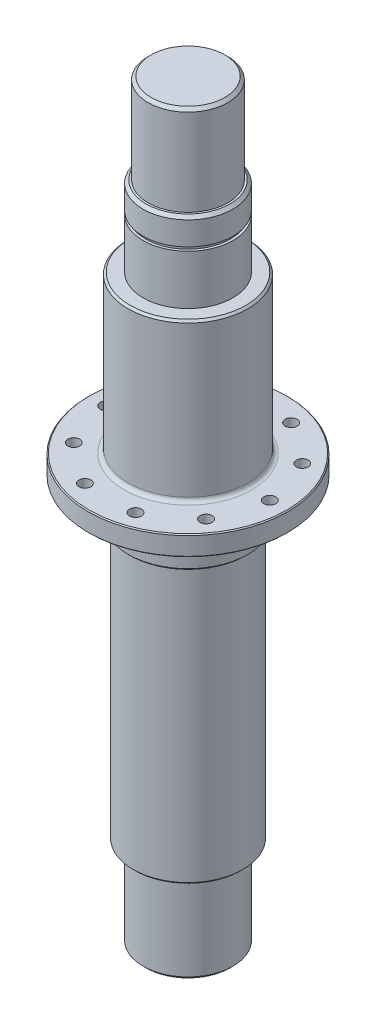
from build123d import *

# Parameters (mm, degrees)
SKIZZE1_R                       = 50
AUFSATZ_LINEAR_AUSTRAGEN1_DEPTH = 10
SKIZZE2_R                       = 3
SCHNITT_LINEAR_AUSTRAGEN2_DEPTH = 10
SKIZZE3_R                       = 30
AUFSATZ_LINEAR_AUSTRAGEN2_DEPTH = 78.6
VERRUNDUNG1_R                   = 2
FASE1_SIZE                      = 1
SKIZZE4_R                       = 22.5
AUFSATZ_LINEAR_AUSTRAGEN3_DEPTH = 24.9
SKIZZE5_R                       = 21.25
AUFSATZ_LINEAR_AUSTRAGEN4_DEPTH = 1.85
SKIZZE6_R                       = 22.5
AUFSATZ_LINEAR_AUSTRAGEN5_DEPTH = 13.25
FASE2_SIZE                      = 1.5
SKIZZE7_R                       = 20
AUFSATZ_LINEAR_AUSTRAGEN6_DEPTH = 45
FASE3_SIZE                      = 1.5
SKIZZE8_R                       = 30
AUFSATZ_LINEAR_AUSTRAGEN7_DEPTH = 20
FASE4_SIZE                      = 1
VERRUNDUNG2_R                   = 2
FASE5_SIZE                      = 0.5
FASE6_SIZE                      = 0.5
SKIZZE9_R                       = 27.5
AUFSATZ_LINEAR_AUSTRAGEN8_DEPTH = 138
SKIZZE10_R                      = 22.5
AUFSATZ_LINEAR_AUSTRAGEN9_DEPTH = 45
VERRUNDUNG3_R                   = 1
FASE7_SIZE                      = 1
VERRUNDUNG4_R                   = 1
FASE8_SIZE                      = 1.5


with BuildPart() as part:
    # Skizze1 → Aufsatz-Linear austragen1 (new body)
    with BuildSketch(Plane(origin=(0, 0, 0), x_dir=(1, 0, 0), z_dir=(0, 1, 0))):
        with Locations(Location((0, 0, 0), (0, 0, 270))):  # turned: the seam where the file's is
            Circle(SKIZZE1_R)
    extrude(amount=AUFSATZ_LINEAR_AUSTRAGEN1_DEPTH)

    # Skizze2 → Schnitt-Linear austragen2 (cut)
    with BuildSketch(Plane(origin=(0, 10, 0), x_dir=(1, 0, 0), z_dir=(0, 1, 0))):
        with Locations(Location((-33.169696769, 24.099195344, 0), (0, 0, 270))):  # turned: the seam where the file's is
            Circle(SKIZZE2_R)
        with Locations(Location((33.169696769, 24.099195344, 0), (0, 0, 270))):  # turned: the seam where the file's is
            Circle(SKIZZE2_R)
        with Locations(Location((12.669696769, 38.993317168, 0), (0, 0, 270))):  # turned: the seam where the file's is
            Circle(SKIZZE2_R)
        with Locations(Location((41, 0, 0), (0, 0, 270))):  # turned: the seam where the file's is
            Circle(SKIZZE2_R)
        with Locations(Location((33.169696769, -24.099195344, 0), (0, 0, 270))):  # turned: the seam where the file's is
            Circle(SKIZZE2_R)
        with Locations(Location((12.669696769, -38.993317168, 0), (0, 0, 270))):  # turned: the seam where the file's is
            Circle(SKIZZE2_R)
        with Locations(Location((-12.669696769, -38.993317168, 0), (0, 0, 270))):  # turned: the seam where the file's is
            Circle(SKIZZE2_R)
        with Locations(Location((-33.169696769, -24.099195344, 0), (0, 0, 270))):  # turned: the seam where the file's is
            Circle(SKIZZE2_R)
        with Locations(Location((-41, 0, 0), (0, 0, 270))):  # turned: the seam where the file's is
            Circle(SKIZZE2_R)
        with Locations(Location((-12.669696769, 38.993317168, 0), (0, 0, 270))):  # turned: the seam where the file's is
            Circle(SKIZZE2_R)
    extrude(amount=-SCHNITT_LINEAR_AUSTRAGEN2_DEPTH, mode=Mode.SUBTRACT)

    # Skizze3 → Aufsatz-Linear austragen2 (add)
    with BuildSketch(Plane(origin=(0, 10, 0), x_dir=(1, 0, 0), z_dir=(0, 1, 0))):
        with Locations(Location((0, 0, 0), (0, 0, 270))):  # turned: the seam where the file's is
            Circle(SKIZZE3_R)
    extrude(amount=AUFSATZ_LINEAR_AUSTRAGEN2_DEPTH)

    # Verrundung1
    verrundung1_edges = [part.edges().sort_by_distance(p)[0] for p in [
        (0, 10, -30),
    ]]
    fillet(verrundung1_edges, radius=VERRUNDUNG1_R)

    # Fase1
    fase1_edges = [part.edges().sort_by_distance(p)[0] for p in [
        (0, 88.6, -30),
    ]]
    chamfer(fase1_edges, length=FASE1_SIZE)

    # Skizze4 → Aufsatz-Linear austragen3 (add)
    with BuildSketch(Plane(origin=(0, 88.6, 0), x_dir=(-1, 0, 0), z_dir=(0, 1, 0))):
        with Locations(Location((0, 0, 0), (0, 0, 90))):  # turned: the seam where the file's is
            Circle(SKIZZE4_R)
    extrude(amount=AUFSATZ_LINEAR_AUSTRAGEN3_DEPTH)

    # Skizze5 → Aufsatz-Linear austragen4 (add)
    with BuildSketch(Plane(origin=(0, 113.5, 0), x_dir=(1, 0, 0), z_dir=(0, 1, 0))):
        with Locations(Location((0, 0, 0), (0, 0, 270))):  # turned: the seam where the file's is
            Circle(SKIZZE5_R)
    extrude(amount=AUFSATZ_LINEAR_AUSTRAGEN4_DEPTH)

    # Skizze6 → Aufsatz-Linear austragen5 (add)
    with BuildSketch(Plane(origin=(0, 115.35, 0), x_dir=(1, 0, 0), z_dir=(0, 1, 0))):
        with Locations(Location((0, 0, 0), (0, 0, 270))):  # turned: the seam where the file's is
            Circle(SKIZZE6_R)
    extrude(amount=AUFSATZ_LINEAR_AUSTRAGEN5_DEPTH)

    # Fase2
    fase2_edges = [part.edges().sort_by_distance(p)[0] for p in [
        (0, 128.6, -22.5),
    ]]
    chamfer(fase2_edges, length=FASE2_SIZE)

    # Skizze7 → Aufsatz-Linear austragen6 (add)
    with BuildSketch(Plane(origin=(0, 128.6, 0), x_dir=(1, 0, 0), z_dir=(0, 1, 0))):
        with Locations(Location((0, 0, 0), (0, 0, 270))):  # turned: the seam where the file's is
            Circle(SKIZZE7_R)
    extrude(amount=AUFSATZ_LINEAR_AUSTRAGEN6_DEPTH)

    # Fase3
    fase3_edges = [part.edges().sort_by_distance(p)[0] for p in [
        (0, 173.6, -20),
    ]]
    chamfer(fase3_edges, length=FASE3_SIZE)

    # Skizze8 → Aufsatz-Linear austragen7 (add)
    with BuildSketch(Plane.XZ):
        with Locations(Location((0, 0, 0), (0, 0, 90))):  # turned: the seam where the file's is
            Circle(SKIZZE8_R)
    extrude(amount=AUFSATZ_LINEAR_AUSTRAGEN7_DEPTH)

    # Fase4
    fase4_edges = [part.edges().sort_by_distance(p)[0] for p in [
        (0, -20, -30),
    ]]
    chamfer(fase4_edges, length=FASE4_SIZE)

    # Verrundung2
    verrundung2_edges = [part.edges().sort_by_distance(p)[0] for p in [
        (0, 0, -30),
    ]]
    fillet(verrundung2_edges, radius=VERRUNDUNG2_R)

    # Fase5
    fase5_edges = [part.edges().sort_by_distance(p)[0] for p in [
        (0, 0, -50),
    ]]
    chamfer(fase5_edges, length=FASE5_SIZE)

    # Fase6
    fase6_edges = [part.edges().sort_by_distance(p)[0] for p in [
        (0, 10, -50),
    ]]
    chamfer(fase6_edges, length=FASE6_SIZE)

    # Skizze9 → Aufsatz-Linear austragen8 (add)
    with BuildSketch(Plane.XZ.offset(20)):
        with Locations(Location((0, 0, 0), (0, 0, 270))):  # turned: the seam where the file's is
            Circle(SKIZZE9_R)
    extrude(amount=AUFSATZ_LINEAR_AUSTRAGEN8_DEPTH)

    # Skizze10 → Aufsatz-Linear austragen9 (add)
    with BuildSketch(Plane.XZ.offset(158)):
        with Locations(Location((0, 0, 0), (0, 0, 90))):  # turned: the seam where the file's is
            Circle(SKIZZE10_R)
    extrude(amount=AUFSATZ_LINEAR_AUSTRAGEN9_DEPTH)

    # Verrundung3
    verrundung3_edges = [part.edges().sort_by_distance(p)[0] for p in [
        (0, -20, 27.5),
    ]]
    fillet(verrundung3_edges, radius=VERRUNDUNG3_R)

    # Fase7
    fase7_edges = [part.edges().sort_by_distance(p)[0] for p in [
        (0, -158, 27.5),
    ]]
    chamfer(fase7_edges, length=FASE7_SIZE)

    # Verrundung4
    verrundung4_edges = [part.edges().sort_by_distance(p)[0] for p in [
        (0, -158, -22.5),
    ]]
    fillet(verrundung4_edges, radius=VERRUNDUNG4_R)

    # Fase8
    fase8_edges = [part.edges().sort_by_distance(p)[0] for p in [
        (0, -203, -22.5),
    ]]
    chamfer(fase8_edges, length=FASE8_SIZE)


solid = part.part
